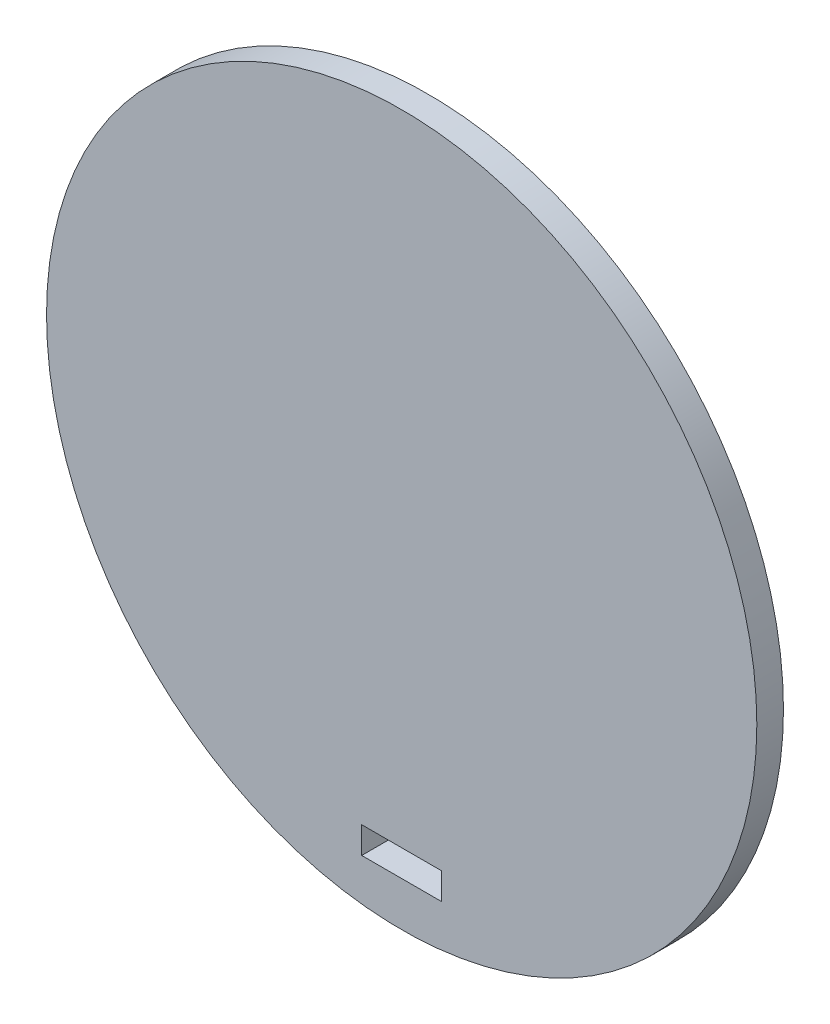
from build123d import *

# Parameters (mm, degrees)
SKETCH1_R           = 40
BOSS_EXTRUDE1_DEPTH = 3
CUT_EXTRUDE1_DEPTH  = 3


with BuildPart() as part:
    # Sketch1 → Boss-Extrude1 (new body)
    with BuildSketch(Plane.XY):
        Circle(SKETCH1_R)
    extrude(amount=BOSS_EXTRUDE1_DEPTH)

    # Sketch2 → Cut-Extrude1 (cut)
    with BuildSketch(Plane(origin=(0, 0, 0), x_dir=(-1, 0, 0), z_dir=(0, 0, -1))):
        Polygon((0, -35), (4.5, -35), (4.5, -32), (-4.5, -32), (-4.5, -35), align=None)
    extrude(amount=-CUT_EXTRUDE1_DEPTH, mode=Mode.SUBTRACT)


solid = part.part
